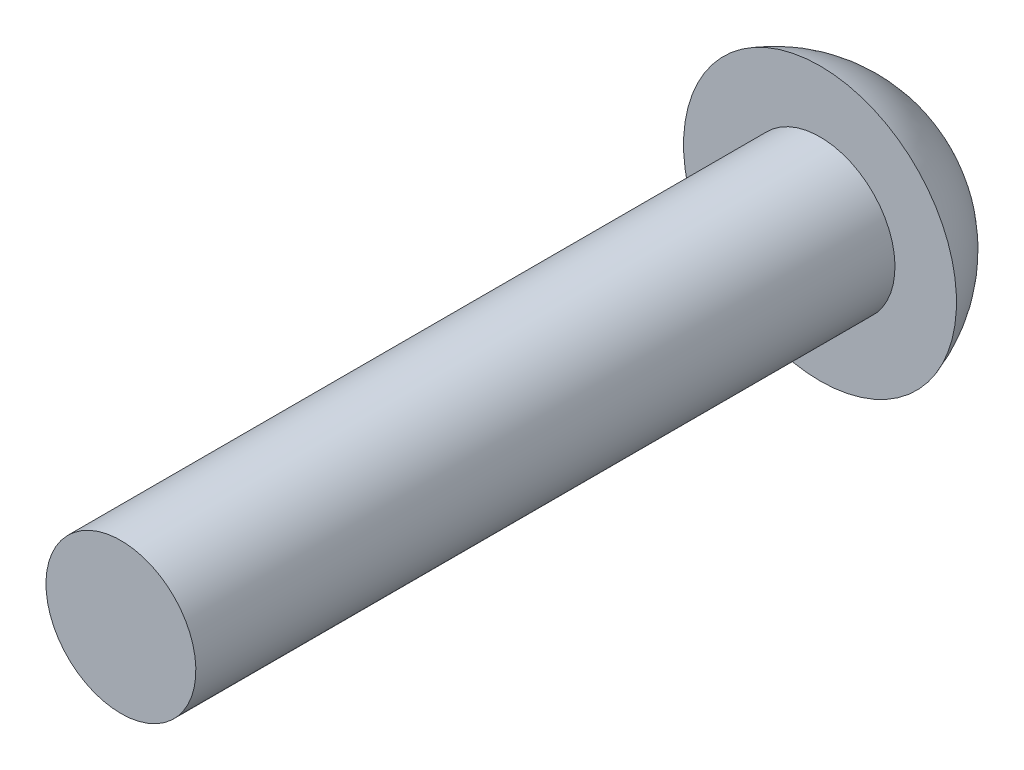
from build123d import *


with BuildPart() as part:
    # Sketch2 → Revolve1 (revolve)
    with BuildSketch(Plane(origin=(0, 0, 0), x_dir=(0, 0, -1), z_dir=(1, 0, 0))):
        with BuildLine():
            Line((0, 0), (0, 1.7018))
            Line((0, 1.7018), (15.875, 1.7018))
            Line((15.875, 1.7018), (15.875, 3.0988))
            ThreePointArc((15.875, 3.0988), (17.493092498, 1.910410982), (18.1102, 0))
            Line((18.1102, 0), (0, 0))
        make_face()
    revolve(axis=Axis((0, 0, 0), (0, 0, -1)))


solid = part.part
